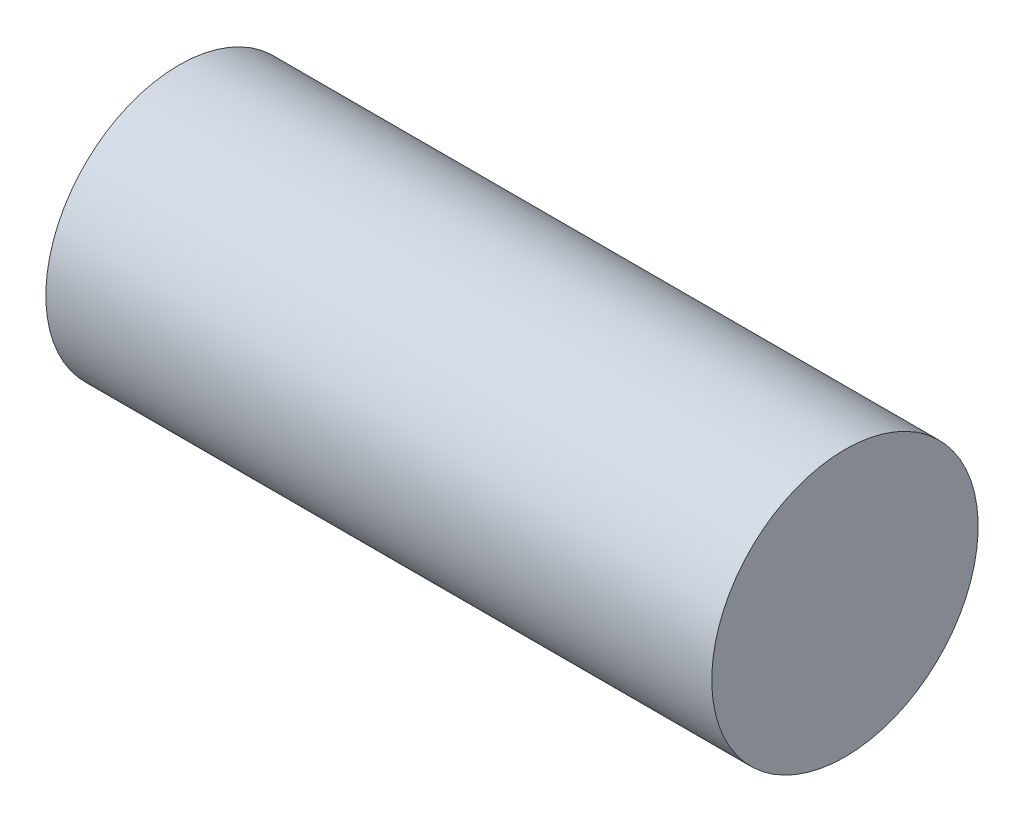
from build123d import *

# Parameters (mm, degrees)
SWEEP1_PROFILE_R = 30


with BuildPart() as part:
    # Sweep1: sweep along a path in Sketch2
    with BuildLine(Plane.XY) as sweep1_path:
        Line((-75, -5), (75, -5))
    # Sweep1 profile (on start of the path) → Sweep1 (sweep)
    with BuildSketch(Plane(origin=(-75, -5, 0), x_dir=(0, 1, 0), z_dir=(1, 0, 0))):
        Circle(SWEEP1_PROFILE_R)
    sweep(path=sweep1_path.line)


solid = part.part
